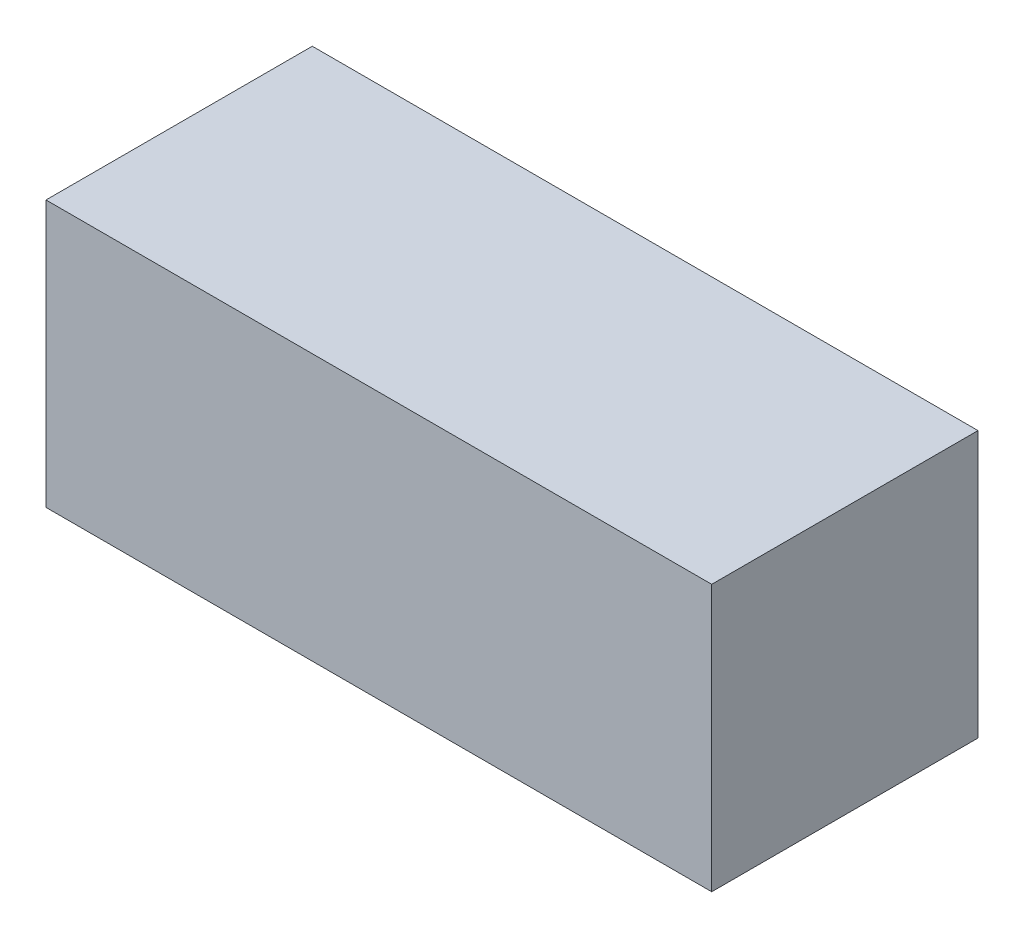
from build123d import *

# Parameters (mm, degrees)
SKETCH_1_W      = 25
SKETCH_1_H      = 10
EXTRUDE_1_DEPTH = 10


with BuildPart() as part:
    # 草图1 → 凸台-拉伸1 (new body)
    with BuildSketch(Plane.XY):
        with Locations((1.121794872, 3.762999132)):
            Rectangle(SKETCH_1_W, SKETCH_1_H)
    extrude(amount=EXTRUDE_1_DEPTH)


solid = part.part
